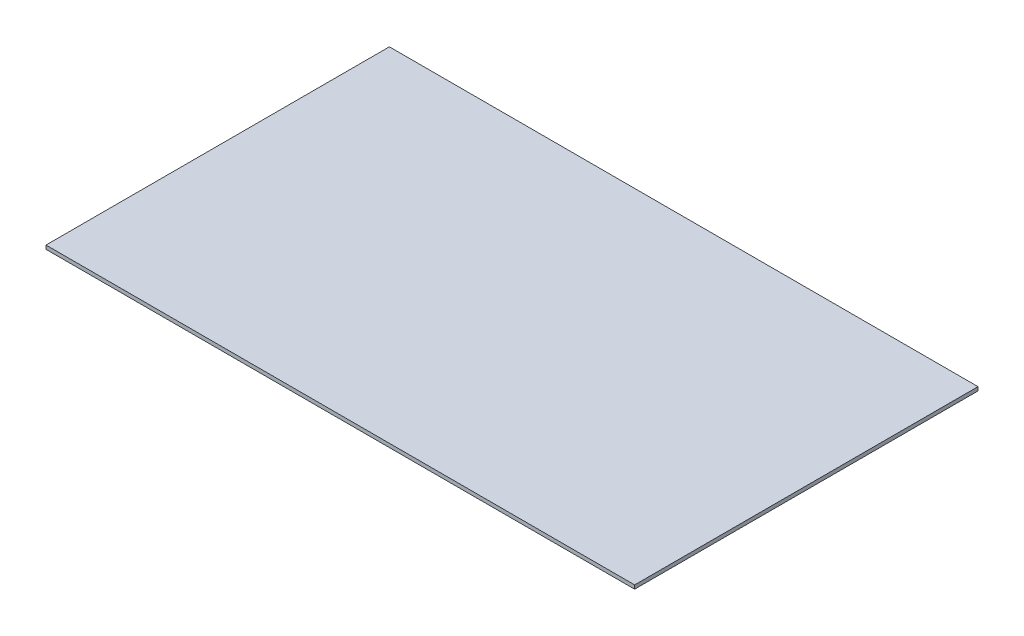
from build123d import *

# Parameters (mm, degrees)
SKETCH1_W           = 60
SKETCH1_H           = 35
BOSS_EXTRUDE1_DEPTH = 0.381


with BuildPart() as part:
    # Sketch1 → Boss-Extrude1 (new body)
    with BuildSketch(Plane(origin=(0, 0, 0), x_dir=(1, 0, 0), z_dir=(0, 1, 0))):
        with Locations((30, 17.5)):
            Rectangle(SKETCH1_W, SKETCH1_H)
    extrude(amount=BOSS_EXTRUDE1_DEPTH)


solid = part.part
